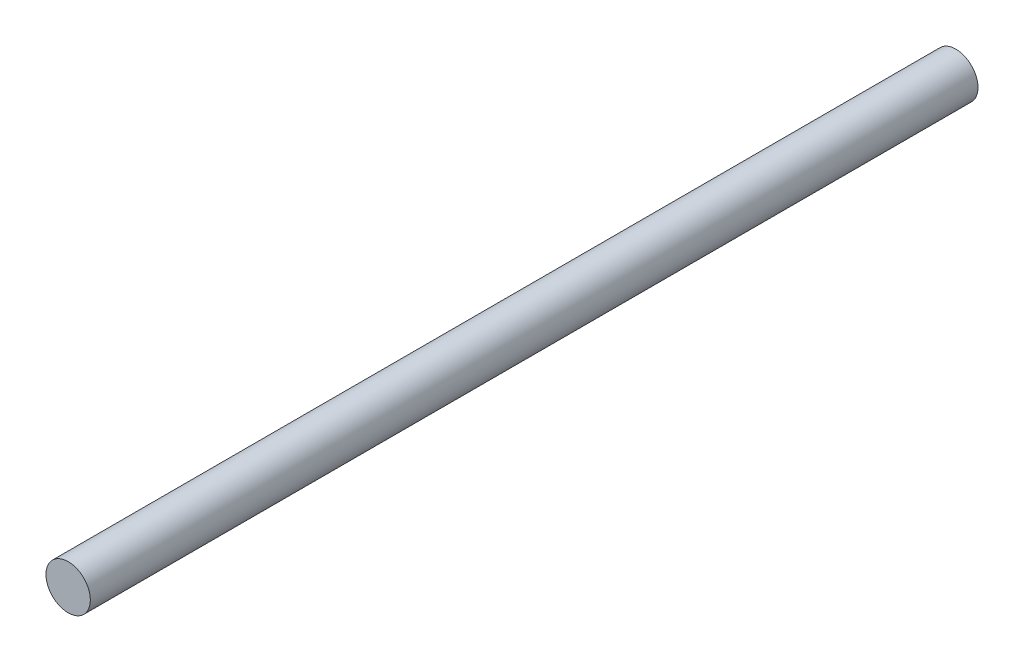
from build123d import *

# Parameters (mm, degrees)
SKETCH1_R           = 1.5
BOSS_EXTRUDE1_DEPTH = 60


with BuildPart() as part:
    # Sketch1 → Boss-Extrude1 (new body)
    with BuildSketch(Plane.XY):
        Circle(SKETCH1_R)
    extrude(amount=BOSS_EXTRUDE1_DEPTH)


solid = part.part
